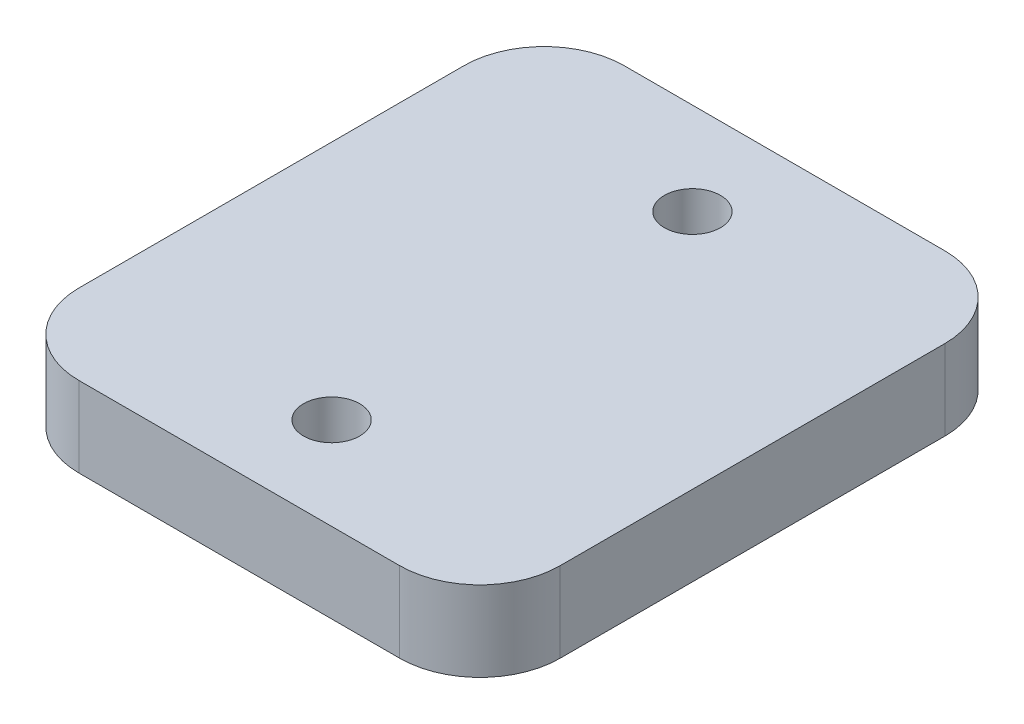
from build123d import *

# Parameters (mm, degrees)
SKETCH1_W           = 30
SKETCH1_H           = 34
BOSS_EXTRUDE1_DEPTH = 5
FILLET2_R           = 5
SKETCH10_R          = 1.75
CUT_EXTRUDE7_DEPTH  = 6
SKETCH11_W          = 3.733694592
SKETCH11_H          = 11
CUT_EXTRUDE8_DEPTH  = 1.2
DRAFT1_ANGLE        = 20
FILLET3_R           = 0.4


with BuildPart() as part:
    # Sketch1 → Boss-Extrude1 (new body)
    with BuildSketch(Plane.XZ.offset(5)):
        Rectangle(SKETCH1_W, SKETCH1_H)
    extrude(amount=-BOSS_EXTRUDE1_DEPTH)

    # Fillet2
    fillet2_edges = [part.edges().sort_by_distance(p)[0] for p in [
        (15, -2.5, 17),
        (15, -2.5, -17),
        (-15, -2.5, -17),
        (-15, -2.5, 17),
    ]]
    fillet(fillet2_edges, radius=FILLET2_R)

    # Sketch10 → Cut-Extrude7 (cut, through all)
    with BuildSketch(Plane.XZ.offset(5)):
        with Locations((0, 11.25)):
            Circle(SKETCH10_R)
        with Locations((0, -11.25)):
            Circle(SKETCH10_R)
    extrude(amount=-CUT_EXTRUDE7_DEPTH, mode=Mode.SUBTRACT)

    # Sketch11 → Cut-Extrude8 (cut)
    with BuildSketch(Plane.XZ.offset(5)):
        with Locations((-12.5, 0)):
            Rectangle(SKETCH11_W, SKETCH11_H)
        with Locations((-7.5, 0)):
            Rectangle(SKETCH11_W, SKETCH11_H)
        with Locations((-2.5, 0)):
            Rectangle(SKETCH11_W, SKETCH11_H)
        with Locations((2.5, 0)):
            Rectangle(SKETCH11_W, SKETCH11_H)
        with Locations((7.5, 0)):
            Rectangle(SKETCH11_W, SKETCH11_H)
        with Locations((12.5, 0)):
            Rectangle(SKETCH11_W, SKETCH11_H)
    extrude(amount=-CUT_EXTRUDE8_DEPTH, mode=Mode.SUBTRACT)

    # Draft1
    draft1_faces = [part.faces().sort_by_distance(p)[0] for p in [
        (10.633152704, -4.4, 0),
        (5.633152704, -4.4, 0),
        (0.633152704, -4.4, 0),
        (-4.366847296, -4.4, 0),
        (-9.366847296, -4.4, 0),
        (-14.366847296, -4.4, 0),
        (14.366847296, -4.4, 0),
        (9.366847296, -4.4, 0),
        (4.366847296, -4.4, 0),
        (-0.633152704, -4.4, 0),
        (-5.633152704, -4.4, 0),
        (-10.633152704, -4.4, 0),
    ]]
    draft(draft1_faces, Plane(origin=(0, -5, 0), x_dir=(0, 0, -1), z_dir=(0, -1, 0)), DRAFT1_ANGLE)

    # Fillet3
    fillet3_edges = [part.edges().sort_by_distance(p)[0] for p in [
        (-13.930083015, -3.8, 0),
        (-11.069916985, -3.8, 0),
        (-14.366847296, -5, 0),
        (-10.633152704, -5, 0),
        (-8.930083015, -3.8, 0),
        (-6.069916985, -3.8, 0),
        (-9.366847296, -5, 0),
        (-5.633152704, -5, 0),
        (-3.930083015, -3.8, 0),
        (-1.069916985, -3.8, 0),
        (-4.366847296, -5, 0),
        (-0.633152704, -5, 0),
        (1.069916985, -3.8, 0),
        (3.930083015, -3.8, 0),
        (0.633152704, -5, 0),
        (4.366847296, -5, 0),
        (6.069916985, -3.8, 0),
        (8.930083015, -3.8, 0),
        (5.633152704, -5, 0),
        (9.366847296, -5, 0),
        (11.069916985, -3.8, 0),
        (13.930083015, -3.8, 0),
        (10.633152704, -5, 0),
        (14.366847296, -5, 0),
    ]]
    fillet(fillet3_edges, radius=FILLET3_R)


solid = part.part
